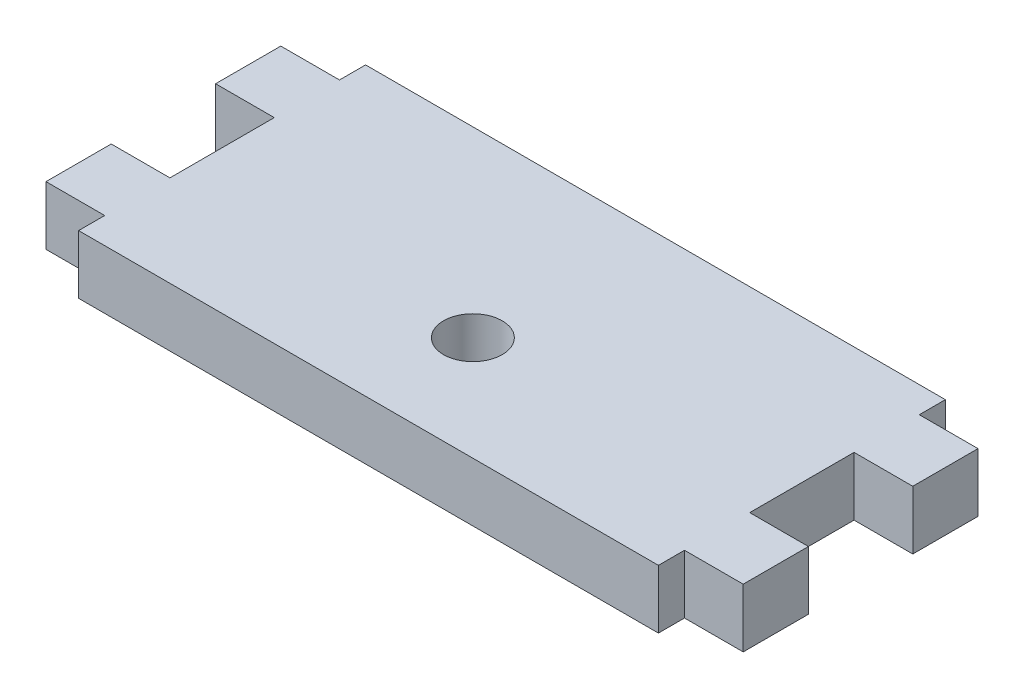
from build123d import *

# Parameters (mm, degrees)
BOSS_EXTRUDE1_DEPTH = 4.5
SKETCH2_R           = 2.25
CUT_EXTRUDE1_DEPTH  = 5.5


with BuildPart() as part:
    # Sketch1 → Boss-Extrude1 (new body)
    with BuildSketch(Plane(origin=(0, 0, 0), x_dir=(1, 0, 0), z_dir=(0, 1, 0))):
        Polygon((-22.225, -9), (-22.225, -11), (0, -11), (0, 11), (-22.225, 11), (-22.225, 9), (-26.725, 9), (-26.725, 4), (-22.225, 4), (-22.225, -4), (-26.725, -4), (-26.725, -9), align=None)
    boss_extrude1 = extrude(amount=BOSS_EXTRUDE1_DEPTH)

    # Mirror1: Boss-Extrude1 across plane
    add(boss_extrude1.mirror(Plane(origin=(0, 4.5, -11), x_dir=(0, 0, 1), z_dir=(-1, 0, 0))))

    # Sketch2 → Cut-Extrude1 (cut, through all)
    with BuildSketch(Plane(origin=(0, 4.5, 0), x_dir=(1, 0, 0), z_dir=(0, 1, 0))):
        with Locations((0, -3)):
            Circle(SKETCH2_R)
    extrude(amount=-CUT_EXTRUDE1_DEPTH, mode=Mode.SUBTRACT)


solid = part.part
